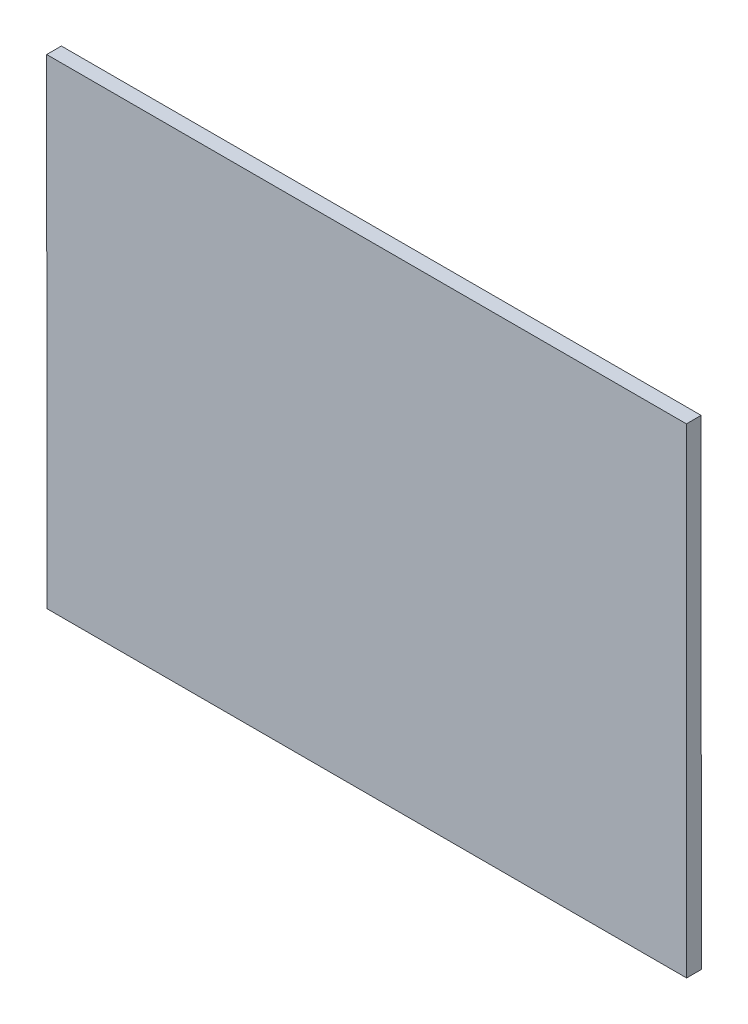
from build123d import *

# Parameters (mm, degrees)
EXTRUDE_1_DEPTH = 2.3


with BuildPart() as part:
    # 草图1 → 凸台-拉伸1 (new body)
    with BuildSketch(Plane.XY):
        Polygon((167.265830553, 85.626483669), (267.262891096, 85.626483669), (267.229967885, 160.626483669), (167.229967885, 160.626483669), align=None)
    extrude(amount=EXTRUDE_1_DEPTH)


solid = part.part
